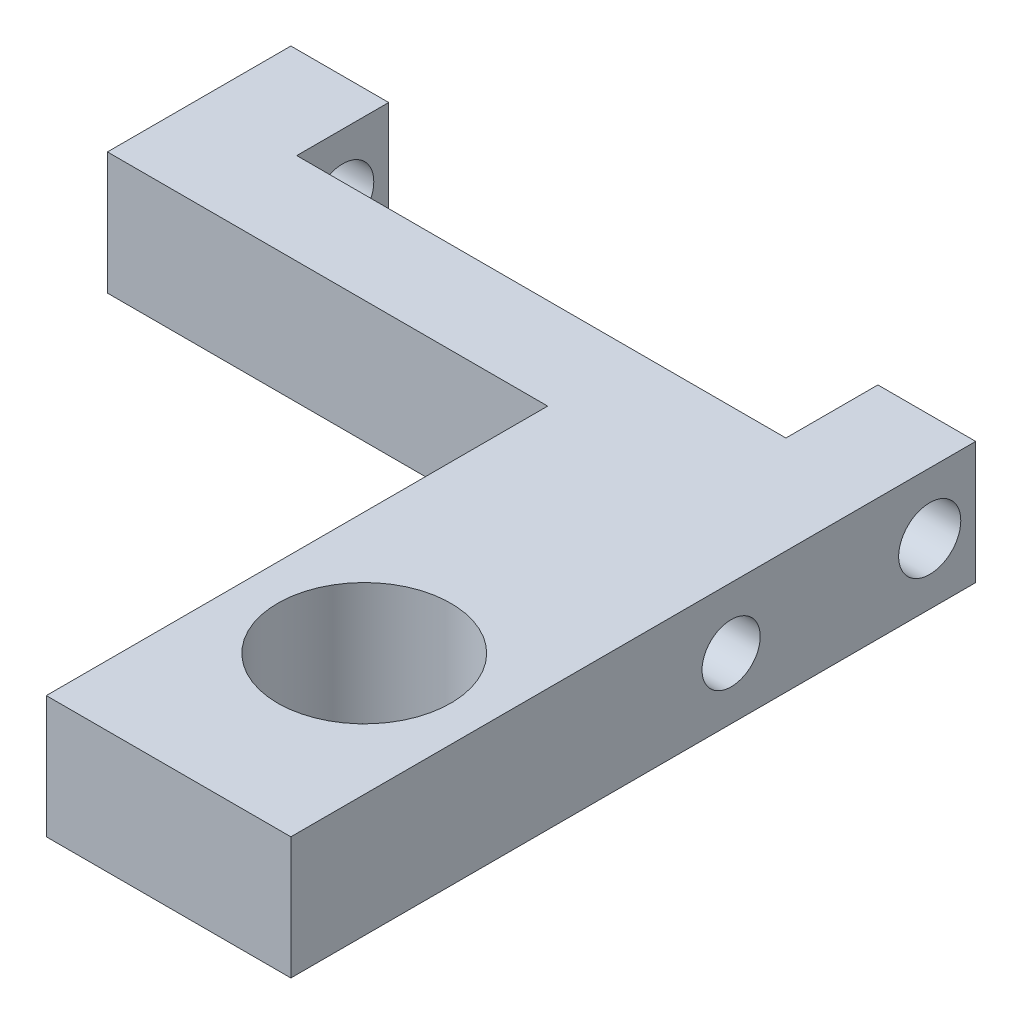
from build123d import *

# Parameters (mm, degrees)
SKETCH1_W             = 17.78
SKETCH1_H             = 17.78
BOSS_EXTRUDE1_DEPTH   = 3.175
SKETCH2_W             = 12.7
SKETCH2_H             = 4.7752
CUT_EXTRUDE1_DEPTH    = 4.175
F_8_CLEARANCE_HOLE1_D = 4.4958
F_0_CLEARANCE_HOLE1_D = 1.6129
F_1_72_TAPPED_HOLE1_D = 1.5113
SKETCH16_W            = 15.75311933
SKETCH16_H            = 13.574133519
CUT_EXTRUDE2_DEPTH    = 4.175


with BuildPart() as part:
    # Sketch1 → Boss-Extrude1 (new body)
    with BuildSketch(Plane(origin=(0, 0, 0), x_dir=(1, 0, 0), z_dir=(0, 1, 0))):
        Rectangle(SKETCH1_W, SKETCH1_H)
    extrude(amount=BOSS_EXTRUDE1_DEPTH)

    # Sketch2 → Cut-Extrude1 (cut, through all)
    with BuildSketch(Plane(origin=(0, 3.175, 0), x_dir=(1, 0, 0), z_dir=(0, 1, 0))):
        with Locations((0, 8.89)):
            Rectangle(SKETCH2_W, SKETCH2_H)
    extrude(amount=-CUT_EXTRUDE1_DEPTH, mode=Mode.SUBTRACT)

    # #8 Clearance Hole1 (through all)
    with Locations(Plane(origin=(0, 3.175, 0), x_dir=(1, 0, 0), z_dir=(0, 1, 0))):
        with Locations((5.715, -3.81)):
            Hole(F_8_CLEARANCE_HOLE1_D / 2)

    # #0 Clearance Hole1 (through all)
    with Locations(Plane(origin=(8.89, 0, 0), x_dir=(0, 0, -1), z_dir=(1, 0, 0))):
        with Locations((7.6962, 1.5875)):
            Hole(F_0_CLEARANCE_HOLE1_D / 2)

    # #1-72 Tapped Hole1 (through all)
    with Locations(Plane(origin=(8.89, 0, 0), x_dir=(0, 0, -1), z_dir=(1, 0, 0))):
        with Locations((2.54, 1.5875)):
            Hole(F_1_72_TAPPED_HOLE1_D / 2)

    # Sketch16 → Cut-Extrude2 (cut, through all)
    with BuildSketch(Plane(origin=(0, 3.175, 0), x_dir=(1, 0, 0), z_dir=(0, 1, 0))):
        with Locations((-5.336559665, -2.65956676)):
            Rectangle(SKETCH16_W, SKETCH16_H)
    extrude(amount=-CUT_EXTRUDE2_DEPTH, mode=Mode.SUBTRACT)


solid = part.part
